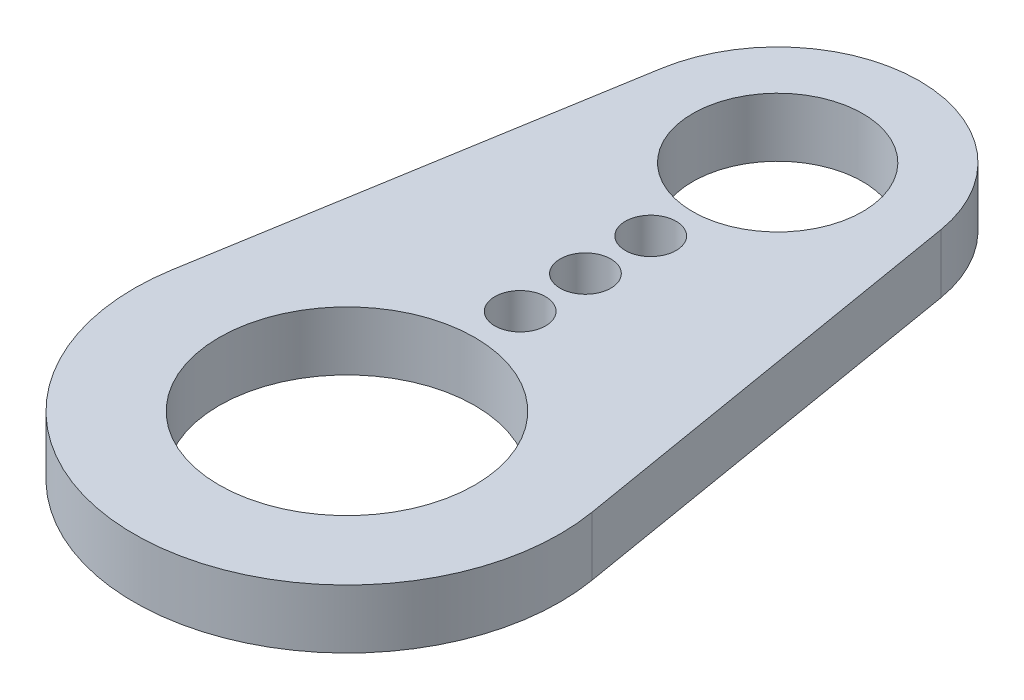
from build123d import *

# Parameters (mm, degrees)
SKETCH1_R      = 3.5814
SKETCH1_R_2    = 0.7112
SKETCH1_R_3    = 2.38125
EXTRUDE1_DEPTH = 0.8255


with BuildPart() as part:
    # Sketch1 → Extrude1 (new body, symmetric)
    with BuildSketch(Plane(origin=(0, 0, 0), x_dir=(1, 0, 0), z_dir=(0, 1, 0))):
        with BuildLine():
            Line((3.914177728, 12.720888158), (5.880660619, 0.985406368))
            ThreePointArc((5.880660619, 0.985406368), (0, -5.96265), (-5.880660619, 0.985406368))
            Line((-5.880660619, 0.985406368), (-3.914177728, 12.720888158))
            ThreePointArc((-3.914177728, 12.720888158), (0, 16.03375), (3.914177728, 12.720888158))
        make_face()
        with Locations(Location((0, 0, 0), (0, 0, 270))):  # turned: the seam where the file's is
            Circle(SKETCH1_R, mode=Mode.SUBTRACT)
        with Locations(Location((0, 4.8514, 0), (0, 0, 270))):  # turned: the seam where the file's is
            Circle(SKETCH1_R_2, mode=Mode.SUBTRACT)
        with Locations(Location((0, 6.6802, 0), (0, 0, 270))):  # turned: the seam where the file's is
            Circle(SKETCH1_R_2, mode=Mode.SUBTRACT)
        with Locations(Location((0, 8.509, 0), (0, 0, 270))):  # turned: the seam where the file's is
            Circle(SKETCH1_R_2, mode=Mode.SUBTRACT)
        with Locations(Location((0, 12.065, 0), (0, 0, 270))):  # turned: the seam where the file's is
            Circle(SKETCH1_R_3, mode=Mode.SUBTRACT)
    extrude(amount=EXTRUDE1_DEPTH, both=True)


solid = part.part
